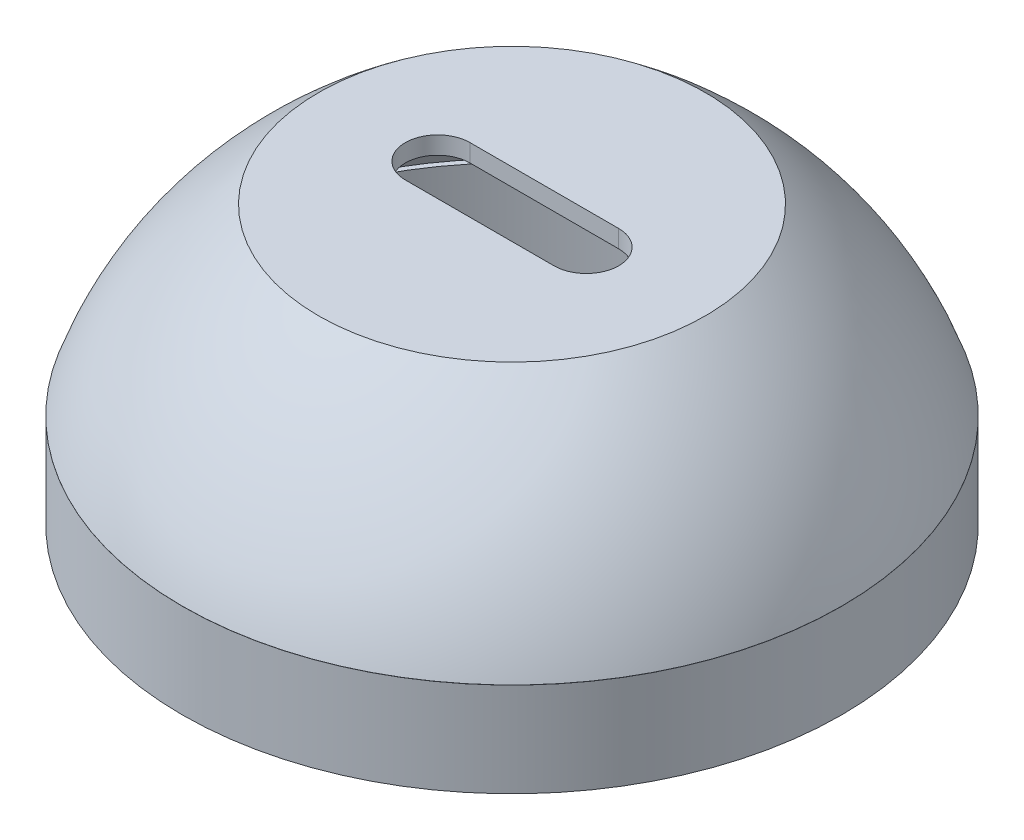
from build123d import *

# Parameters (mm, degrees)
SKETCH3_W          = 2.964832231
SKETCH3_H          = 14.108919269
CUT_EXTRUDE3_DEPTH = 10


with BuildPart() as part:
    # Sketch2 → Revolve1 (revolve)
    with BuildSketch(Plane.XY):
        with BuildLine():
            Line((0, 0), (29, 0))
            add(Edge.make_bspline(
                [(29, 0), (43.973856775, -11.403607847), (49.432853271, -27.473975523)],
                knots=[0, 0, 0, 0.848255364, 0.848255364, 0.848255364], degree=2))
            Line((49.432853271, -27.473975523), (47.224927371, -27.473975523))
            add(Edge.make_bspline(
                [(47.224927371, -27.473975523), (40.235215176, -12.081344627), (27.590919343, -2.643455387)],
                knots=[0, 0, 0, 0.915287791, 0.915287791, 0.915287791], degree=2))
            Line((27.590919343, -2.643455387), (0, -2.643455387))
            Line((0, -2.643455387), (0, 0))
        make_face()
    revolve(axis=Axis((0, 39.692648139, 0), (0, -1, 0)))

    # Sketch6 → Cut-Extrude3 (cut)
    with BuildSketch(Plane(origin=(0, 0, 0), x_dir=(1, 0, 0), z_dir=(0, 1, 0))):
        with BuildLine():
            Line((-11.15, 4.85), (11.15, 4.85))
            ThreePointArc((11.15, 4.85), (16, 0), (11.15, -4.85))
            Line((11.15, -4.85), (-11.15, -4.85))
            ThreePointArc((-11.15, -4.85), (-16, 0), (-11.15, 4.85))
        make_face()
    extrude(amount=-CUT_EXTRUDE3_DEPTH, mode=Mode.SUBTRACT)


with BuildPart() as body_2:
    # Sketch3 → Revolve2 (revolve)
    with BuildSketch(Plane.XY):
        with Locations((47.950437156, -34.546192387)):
            Rectangle(SKETCH3_W, SKETCH3_H)
    revolve(axis=Axis((0, 0, 0), (0, -1, 0)))


solid = Compound([part.part, body_2.part])
